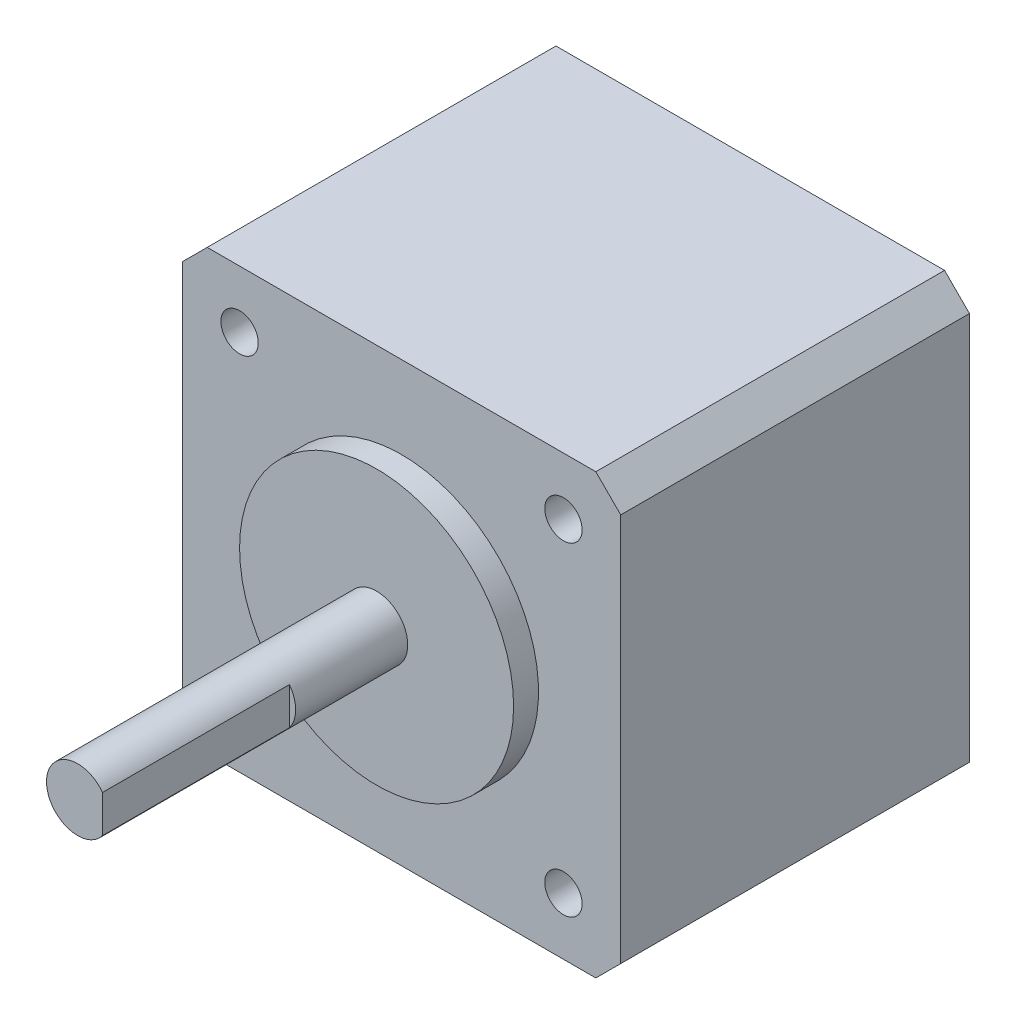
from build123d import *

# Parameters (mm, degrees)
ESQUISSE2_W             = 35.2
ESQUISSE2_H             = 35.2
BOSS_EXTRU_1_DEPTH      = 28
ESQUISSE3_R             = 11
BOSS_EXTRU_2_DEPTH      = 2
ESQUISSE4_R             = 2.5
BOSS_EXTRU_3_DEPTH      = 24
ENL_V_START             = -15
ENL_V_MAT_EXTRU_1_DEPTH = 15
CHANFREIN1_SIZE         = 2
ESQUISSE6_R             = 1.5
ENL_V_MAT_EXTRU_2_DEPTH = 4.5


with BuildPart() as part:
    # Esquisse2 → Boss.-Extru.1 (new body)
    with BuildSketch(Plane.XY):
        with Locations((17.6, 17.6)):
            Rectangle(ESQUISSE2_W, ESQUISSE2_H)
    extrude(amount=BOSS_EXTRU_1_DEPTH)

    # Esquisse3 → Boss.-Extru.2 (add)
    with BuildSketch(Plane.XY.offset(28)):
        with Locations((17.6, 17.6)):
            Circle(ESQUISSE3_R)
    extrude(amount=BOSS_EXTRU_2_DEPTH)

    # Esquisse4 → Boss.-Extru.3 (add)
    with BuildSketch(Plane.XY.offset(30)):
        with Locations((17.6, 17.6)):
            Circle(ESQUISSE4_R)
    extrude(amount=BOSS_EXTRU_3_DEPTH)

    # Esquisse5 → Enlèv. mat.-Extru.1 (cut)
    with BuildSketch(Plane.XY.offset(54).offset(ENL_V_START)):
        with BuildLine():
            Line((19.6, 19.1), (19.6, 16.1))
            ThreePointArc((19.6, 16.1), (20.1, 17.6), (19.6, 19.1))
        make_face()
    extrude(amount=ENL_V_MAT_EXTRU_1_DEPTH, mode=Mode.SUBTRACT)

    # Chanfrein1
    chanfrein1_edges = [part.edges().sort_by_distance(p)[0] for p in [
        (0, 0, 14),
        (35.2, 0, 14),
        (0, 35.2, 14),
        (35.2, 35.2, 14),
    ]]
    chamfer(chanfrein1_edges, length=CHANFREIN1_SIZE)

    # Esquisse6 → Enlèv. mat.-Extru.2 (cut)
    with BuildSketch(Plane.XY.offset(28)):
        with Locations((30.6, 30.6)):
            Circle(ESQUISSE6_R)
        with Locations((30.6, 4.6)):
            Circle(ESQUISSE6_R)
        with Locations((4.6, 4.6)):
            Circle(ESQUISSE6_R)
        with Locations((4.6, 30.6)):
            Circle(ESQUISSE6_R)
    extrude(amount=-ENL_V_MAT_EXTRU_2_DEPTH, mode=Mode.SUBTRACT)


solid = part.part
